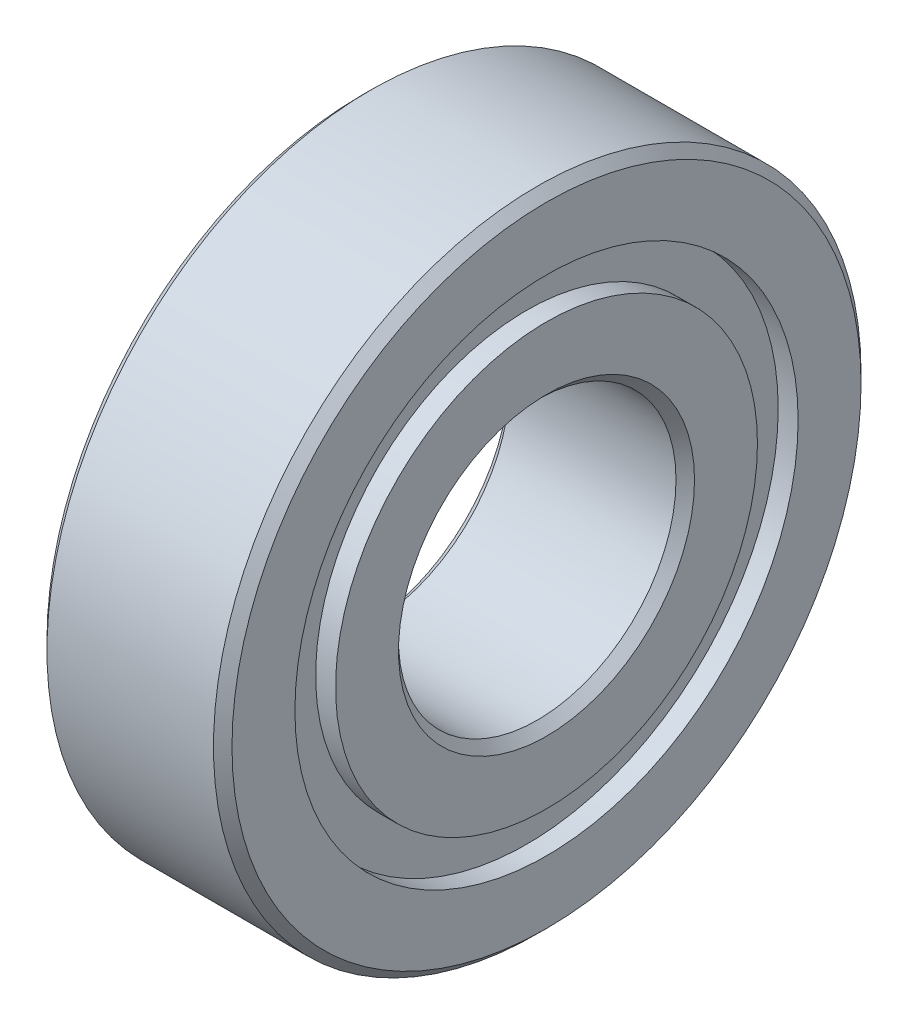
from build123d import *


with BuildPart() as part:
    # Sketch1 → Revolve1 (revolve)
    with BuildSketch(Plane.XY):
        Polygon((4, 13.6), (3.6, 14), (-3.6, 14), (-4, 13.6), (-4, 10.879120879), (-3.13888889, 10.879120879), (-3.13888889, 9.120879121), (-4, 9.120879121), (-4, 6.4), (-3.6, 6), (3.6, 6), (4, 6.4), (4, 9.120879121), (3.13888889, 9.120879121), (3.13888889, 10.879120879), (4, 10.879120879), align=None)
    revolve(axis=Axis((-4, 0, 0), (1, 0, 0)))


solid = part.part
